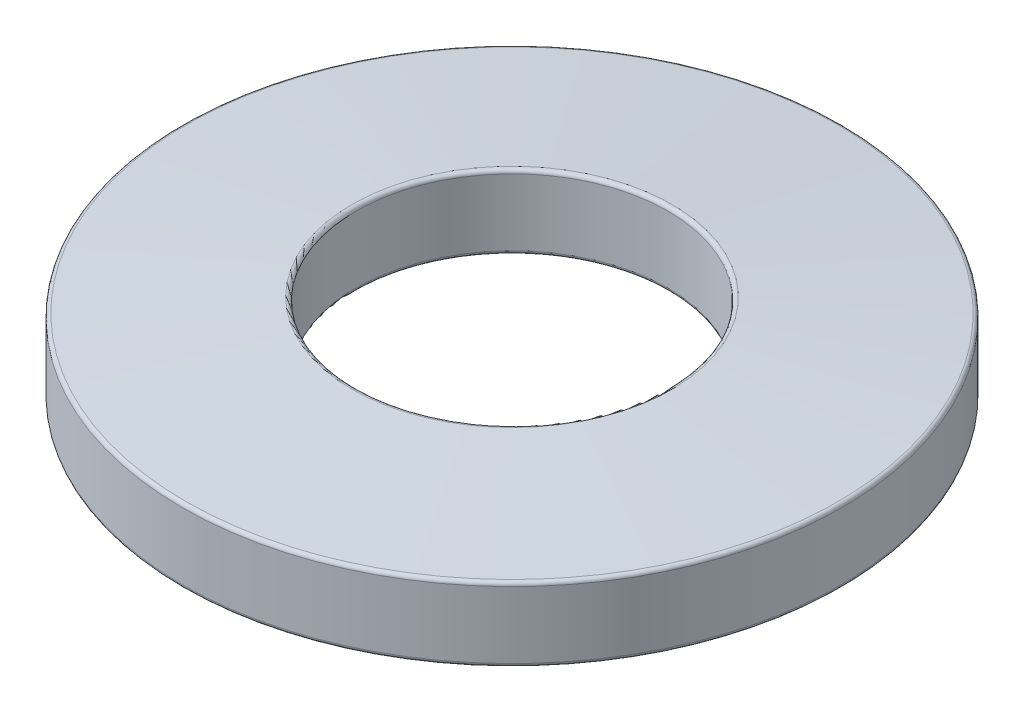
from build123d import *

# Parameters (mm, degrees)
FILLET1_R = 0.254


with BuildPart() as part:
    # Sketch2 → Revolve1 (revolve)
    with BuildSketch(Plane(origin=(0, 0, 0), x_dir=(0, 0, -1), z_dir=(1, 0, 0))):
        Polygon((10.5791, 6.0325), (10.5791, 1.0033), (22.352, 0), (22.352, 5.0292), align=None)
    revolve(axis=Axis((0, 0, 0), (0, 1, 0)))

    # Fillet1
    fillet1_edges = [part.edges().sort_by_distance(p)[0] for p in [
        (0, 5.0292, 22.352),
        (0, 0, 22.352),
        (0, 1.0033, 10.5791),
        (0, 6.0325, 10.5791),
    ]]
    fillet(fillet1_edges, radius=FILLET1_R)


solid = part.part
